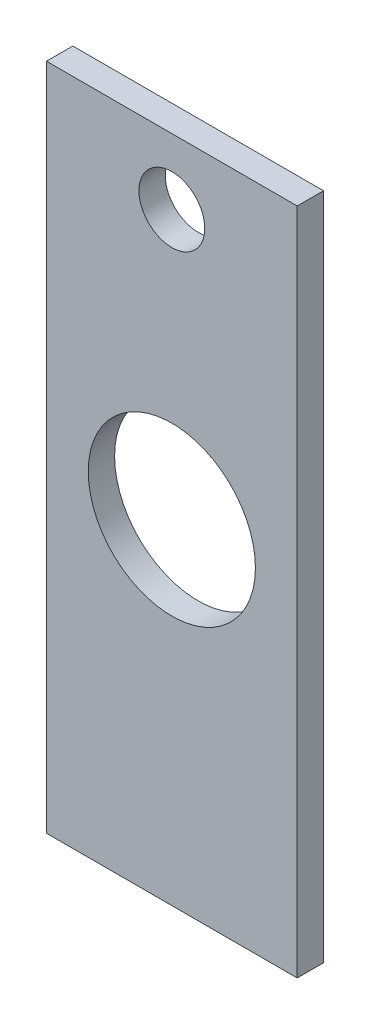
from build123d import *

# Parameters (mm, degrees)
SKETCH1_W                    = 19.05
SKETCH1_H                    = 50.8
SKETCH1_R                    = 6.35
BOSS_EXTRUDE1_DEPTH          = 2
F_5_0_5_DIAMETER_HOLE1_D     = 5
F_5_0_5_DIAMETER_HOLE1_DEPTH = 5
F_5_0_5_DIAMETER_HOLE1_TIP   = 1.502151548


with BuildPart() as part:
    # Sketch1 → Boss-Extrude1 (new body)
    with BuildSketch(Plane.XY):
        Rectangle(SKETCH1_W, SKETCH1_H)
        Circle(SKETCH1_R, mode=Mode.SUBTRACT)
    extrude(amount=BOSS_EXTRUDE1_DEPTH)

    # Ø5.0 (5) Diameter Hole1
    with Locations(Plane(origin=(0, 0, 0), x_dir=(-1, 0, 0), z_dir=(0, 0, -1))):
        with Locations((0, 20.4)):
            Hole(F_5_0_5_DIAMETER_HOLE1_D / 2, depth=F_5_0_5_DIAMETER_HOLE1_DEPTH)
            with Locations((0, 0, -(F_5_0_5_DIAMETER_HOLE1_DEPTH + F_5_0_5_DIAMETER_HOLE1_TIP / 2))):  # 118° drill point
                Cone(0, F_5_0_5_DIAMETER_HOLE1_D / 2, F_5_0_5_DIAMETER_HOLE1_TIP, mode=Mode.SUBTRACT)


solid = part.part
